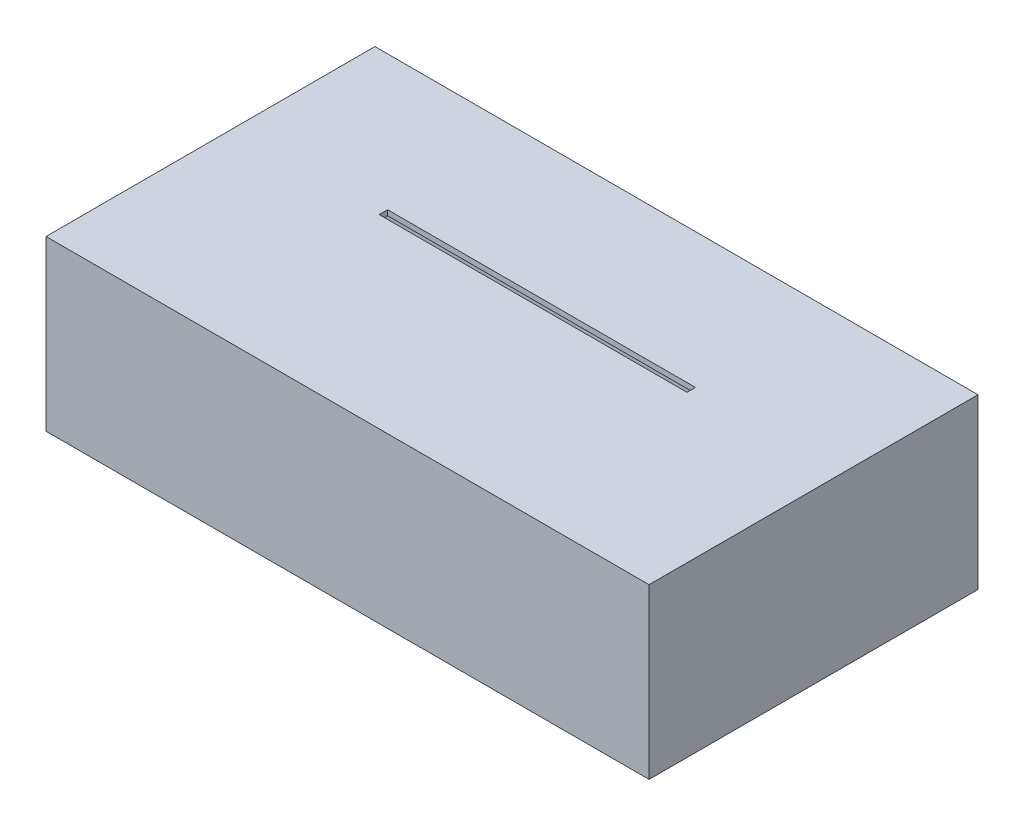
from build123d import *

# Parameters (mm, degrees)
SKETCH1_W           = 454.025
SKETCH1_H           = 247.65
BOSS_EXTRUDE1_DEPTH = 127
SHELL1_T            = -3.937
SKETCH3_W           = 231.775
SKETCH3_H           = 6.35
CUT_EXTRUDE1_DEPTH  = 128
BOSS_EXTRUDE2_DEPTH = 4.191
BOSS_EXTRUDE3_DEPTH = 4.191
SKETCH6_W           = 4.191
SKETCH6_H           = 12.7
CUT_EXTRUDE2_DEPTH  = 5.08


with BuildPart() as part:
    # Sketch1 → Boss-Extrude1 (new body)
    with BuildSketch(Plane(origin=(0, 0, 0), x_dir=(1, 0, 0), z_dir=(0, 1, 0))):
        Rectangle(SKETCH1_W, SKETCH1_H)
    extrude(amount=BOSS_EXTRUDE1_DEPTH)

    # Shell1
    shell1_openings = [part.faces().sort_by_distance(p)[0] for p in [
        (0, 0, 0),
    ]]
    offset(amount=SHELL1_T, openings=shell1_openings, kind=Kind.INTERSECTION)

    # Sketch3 → Cut-Extrude1 (cut, through all)
    with BuildSketch(Plane(origin=(0, 127, 0), x_dir=(1, 0, 0), z_dir=(0, 1, 0))):
        with Locations((0, 19.05)):
            Rectangle(SKETCH3_W, SKETCH3_H)
    extrude(amount=-CUT_EXTRUDE1_DEPTH, mode=Mode.SUBTRACT)


with BuildPart() as body_2:
    # Sketch4 → Boss-Extrude2 (new body)
    with BuildSketch(Plane.XZ):
        Polygon((118.4275, 119.888), (118.4275, 108.393628317), (-118.4275, 108.393628317), (-118.4275, 119.888), (-223.0755, 119.888), (-223.0755, -119.888), (223.0755, -119.888), (223.0755, 119.888), align=None)
    extrude(amount=-BOSS_EXTRUDE2_DEPTH)

    # Sketch6 → Cut-Extrude2 (cut)
    with BuildSketch(Plane.XZ):
        with Locations((-113.792, 68.497674129)):
            Rectangle(SKETCH6_W, SKETCH6_H)
        with Locations((-113.792, 18.415)):
            Rectangle(SKETCH6_W, SKETCH6_H)
        with Locations((113.792, 18.415)):
            Rectangle(SKETCH6_W, SKETCH6_H)
        with Locations((113.792, 68.497674129)):
            Rectangle(SKETCH6_W, SKETCH6_H)
        with BuildLine():
            Line((-116.68125, -21.43125), (-116.68125, -15.875))
            Line((-116.68125, -15.875), (116.68125, -15.875))
            Line((116.68125, -15.875), (116.68125, -21.43125))
            ThreePointArc((116.68125, -21.43125), (116.216282015, -22.553782015), (115.09375, -23.01875))
            Line((115.09375, -23.01875), (-115.09375, -23.01875))
            ThreePointArc((-115.09375, -23.01875), (-116.216282015, -22.553782015), (-116.68125, -21.43125))
        make_face()
    extrude(amount=-CUT_EXTRUDE2_DEPTH, mode=Mode.SUBTRACT)


with BuildPart() as body_3:
    # Sketch5 → Boss-Extrude3 (new body)
    with BuildSketch(Plane(origin=(-115.8875, 0, 0), x_dir=(0, 0, -1), z_dir=(1, 0, 0))):
        Polygon((-100.247674129, 2.413), (-18.415, 61.384810708), (13.335, 61.384810708), (13.335, 2.413), (-12.065, 2.413), (-12.065, -1.905), (-24.765, -1.905), (-24.765, 2.413), (-62.147674129, 2.413), (-62.147674129, -1.905), (-74.847674129, -1.905), (-74.847674129, 2.413), align=None)
    extrude(amount=BOSS_EXTRUDE3_DEPTH)


with BuildPart() as body_4:
    # Mirror2: mirrored copy
    add(body_3.part.mirror(Plane(origin=(0, 0, 0), x_dir=(0, 0, 1), z_dir=(1, 0, 0))))


solid = Compound([part.part, body_2.part, body_3.part, body_4.part])
